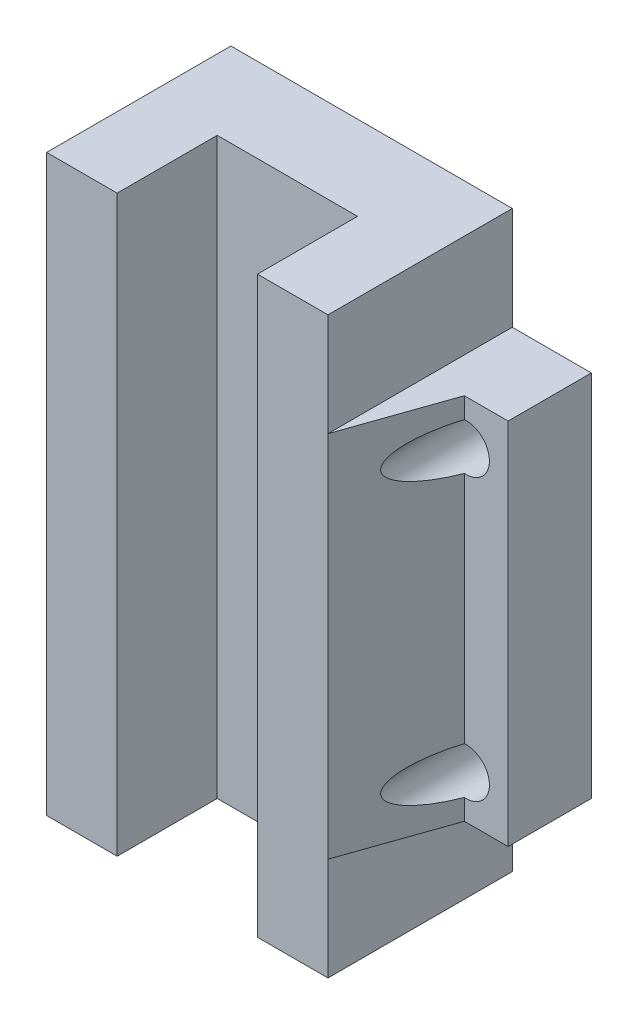
from build123d import *

# Parameters (mm, degrees)
SKETCH_5_W          = 47
SKETCH_5_H          = 19.7
EXTRUDE_3_DEPTH     = 61.4
CUT_EXTRUDE_1_DEPTH = 67.477308158
CUT_EXTRUDE_2_DEPTH = 11
SKETCH_8_R          = 2.5
CUT_EXTRUDE_3_DEPTH = 33
SKETCH_9_W          = 15
SKETCH_9_H          = 21.981640809
CUT_EXTRUDE_4_DEPTH = 73


with BuildPart() as part:
    # 草图5 → 凸台-拉伸3 (new body)
    with BuildSketch(Plane(origin=(0, 0, 0), x_dir=(1, 0, 0), z_dir=(0, 1, 0))):
        Rectangle(SKETCH_5_W, SKETCH_5_H)
    extrude(amount=EXTRUDE_3_DEPTH)

    # 草图6 → 切除-拉伸1 (cut, through all)
    with BuildSketch(Plane(origin=(0, 61.4, 0), x_dir=(1, 0, 0), z_dir=(0, 1, 0))):
        Polygon((-18.819510237, 0.95), (-23.5, 0.95), (-23.5, -9.85), (-15.040666545, -9.85), align=None)
        Polygon((18.819510237, 0.95), (15.040666545, -9.85), (23.5, -9.85), (23.5, 0.95), align=None)
    extrude(amount=-CUT_EXTRUDE_1_DEPTH, mode=Mode.SUBTRACT)

    # 草图6<6> → 切除-拉伸2 (cut)
    with BuildSketch(Plane(origin=(0, 61.4, 0), x_dir=(1, 0, 0), z_dir=(0, 1, 0))):
        Polygon((-19, 9.85), (-23.5, 9.85), (-23.5, 0.95), (-18.819510237, 0.95), (-15.040666545, -9.85), (-15.040666545, 9.85), align=None)
        Polygon((19, 9.85), (15.040666545, 9.85), (15.040666545, -9.85), (18.819510237, 0.95), (23.5, 0.95), (23.5, 9.85), align=None)
    cut_extrude_2 = extrude(amount=-CUT_EXTRUDE_2_DEPTH, mode=Mode.SUBTRACT)

    # 镜向1: 切除-拉伸2 across plane
    add(cut_extrude_2.mirror(Plane.ZX.offset(30.7)), mode=Mode.SUBTRACT)

    # 草图8 → 切除-拉伸3 (cut)
    with BuildSketch(Plane(origin=(0, 0, -9.85), x_dir=(-1, 0, 0), z_dir=(0, 0, -1))):
        with Locations((-19, 45.7)):
            Circle(SKETCH_8_R)
        with Locations((-19, 15.7)):
            Circle(SKETCH_8_R)
        with Locations((19, 15.7)):
            Circle(SKETCH_8_R)
        with Locations((19, 45.7)):
            Circle(SKETCH_8_R)
    extrude(amount=-CUT_EXTRUDE_3_DEPTH, mode=Mode.SUBTRACT)

    # 草图9 → 切除-拉伸4 (cut)
    with BuildSketch(Plane.XZ):
        with Locations((0, 10.140820404)):
            Rectangle(SKETCH_9_W, SKETCH_9_H)
    extrude(amount=-CUT_EXTRUDE_4_DEPTH, mode=Mode.SUBTRACT)


solid = part.part
